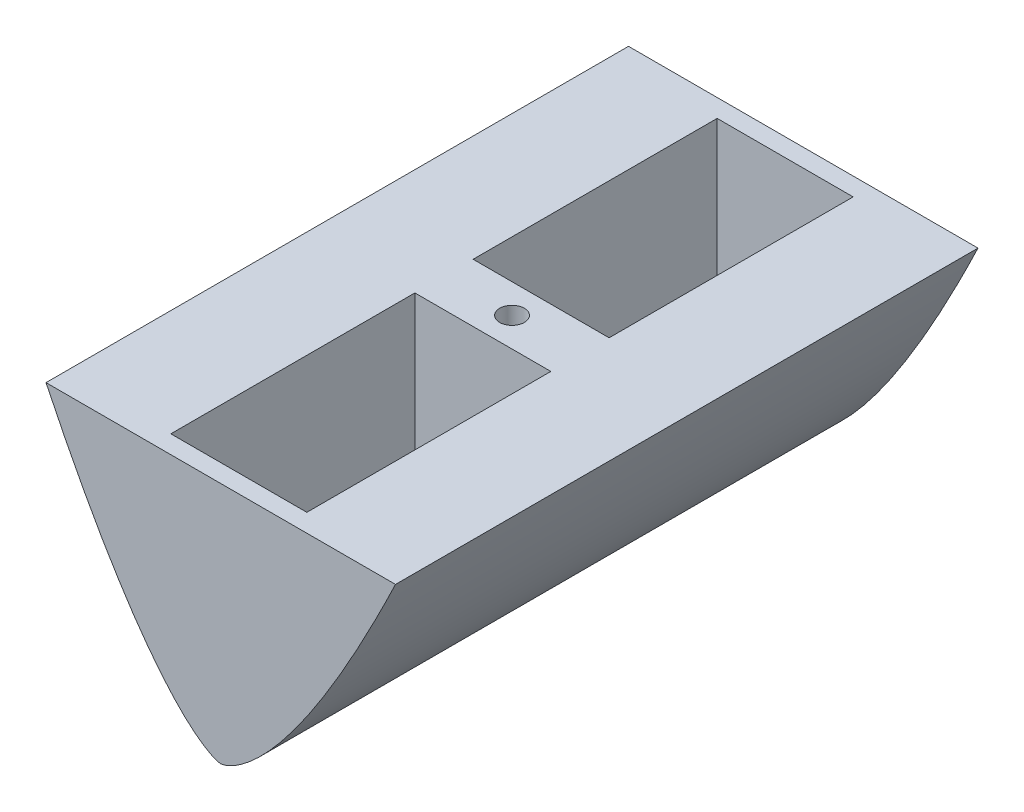
from build123d import *

# Parameters (mm, degrees)
BOSS_EXTRUDE1_DEPTH = 150
SKETCH2_W           = 70.04
SKETCH2_H           = 125.682
CUT_EXTRUDE1_DEPTH  = 92.52
SKETCH4_R           = 6.35
CUT_EXTRUDE2_DEPTH  = 126.0000001


with BuildPart() as part:
    # Sketch1 → Boss-Extrude1 (new body, symmetric)
    with BuildSketch(Plane.XY):
        with BuildLine():
            Line((-90, 0), (90, 0))
            add(Edge.make_bspline(
                [(0, -125), (0.040524176, -125), (0.132680738, -124.994439857), (0.341916524, -124.973583458), (0.719215848, -124.916748559), (1.289359309, -124.795671245), (2.111250987, -124.564993976), (3.188188494, -124.185399035), (4.55335692, -123.602067095), (6.240024265, -122.749483932), (8.303485367, -121.537471112), (10.724338253, -119.906336414), (13.709224486, -117.633146505), (17.125270454, -114.69999474), (20.824901988, -111.164506709), (25.639167248, -106.109725012), (30.222189081, -100.781084362), (34.598208113, -95.283505936), (38.779692195, -89.68464193), (42.033720965, -85.139153723), (45.998570642, -79.385140077), (50.607665842, -72.379869472), (55.055097052, -65.270591126), (59.364717318, -58.077727616), (62.873506602, -52.034941709), (65.634088968, -47.174450031), (68.351556299, -42.288964471), (71.027719256, -37.382091987), (73.66630476, -32.452622561), (76.267043416, -27.507038124), (78.515032858, -23.158839582), (80.417537293, -19.429534292), (81.996088861, -16.30213476), (83.240093312, -13.819613379), (84.499261394, -11.286158088), (85.71049431, -8.833707245), (86.985510696, -6.229974473), (88.124916321, -3.890806906), (89.16581329, -1.735067221), (89.725029899, -0.572854377), (90, 0)],
                knots=[0, 0, 0, 0, 0, 0.001033937, 0.002067874, 0.004832108, 0.008888532, 0.014521939, 0.021877134, 0.03129786, 0.043316303, 0.058339394, 0.077368645, 0.098985233, 0.130325067, 0.162749734, 0.196051037, 0.260900538, 0.293325324, 0.325750109, 0.358174889, 0.390599669, 0.455449159, 0.520298707, 0.552723499, 0.585148291, 0.617573035, 0.64999778, 0.682422553, 0.714847326, 0.747272095, 0.779696863, 0.795909248, 0.812121632, 0.828334016, 0.844546401, 0.860758801, 0.8769712, 0.8931836, 0.909396, 0.909396, 0.909396, 0.909396, 0.909396], degree=4))
            add(Edge.make_bspline(
                [(-90, 0), (-89.728779922, -0.56504183), (-89.1769697, -1.71190114), (-88.152296829, -3.83418854), (-87.025621632, -6.14778151), (-85.77024086, -8.712054514), (-84.575010931, -11.133133097), (-83.333486196, -13.632337314), (-82.107980727, -16.079385385), (-80.861307848, -18.551268163), (-79.614724115, -21.003198373), (-78.041946947, -24.073051937), (-76.14112023, -27.74330145), (-73.897620216, -32.01583355), (-71.29937439, -36.878159088), (-68.66345797, -41.721432974), (-65.319600127, -47.747831092), (-61.905775094, -53.735451599), (-58.415392446, -59.678580549), (-54.124522247, -66.749179037), (-50.456908111, -72.584773085), (-46.686198982, -78.354608666), (-42.019654617, -85.183243955), (-37.197162592, -91.90350945), (-31.965949682, -98.694375088), (-26.424011931, -105.23527848), (-21.505077303, -110.483804706), (-17.625792471, -114.241326427), (-14.180324535, -117.24850825), (-11.12345498, -119.618653213), (-8.635573143, -121.326761696), (-6.508658653, -122.601737804), (-4.768184737, -123.501182231), (-3.361883797, -124.117294089), (-2.239283334, -124.524207657), (-1.381983723, -124.772747972), (-0.756173, -124.911034051), (-0.347330621, -124.973877644), (-0.123395647, -124.995337069), (-0.020504111, -125), (0, -125)],
                knots=[0.090604, 0.090604, 0.090604, 0.090604, 0.090604, 0.106595296, 0.122586593, 0.138577889, 0.154569185, 0.17056047, 0.186551755, 0.202543039, 0.218534324, 0.234525598, 0.250516872, 0.282499419, 0.314481991, 0.346464563, 0.378447155, 0.410429746, 0.474394817, 0.506377414, 0.538360012, 0.602325099, 0.634307686, 0.666290273, 0.730255401, 0.794220554, 0.833134059, 0.865116625, 0.897099301, 0.919478736, 0.939186072, 0.954818476, 0.967077107, 0.976978528, 0.984613115, 0.990416572, 0.994763934, 0.997672431, 0.999476856, 1, 1, 1, 1, 1], degree=4))
        make_face()
    extrude(amount=BOSS_EXTRUDE1_DEPTH, both=True)

    # Sketch2 → Cut-Extrude1 (cut)
    with BuildSketch(Plane(origin=(0, 0, 0), x_dir=(1, 0, 0), z_dir=(0, 1, 0))):
        with Locations((0, 77.841)):
            Rectangle(SKETCH2_W, SKETCH2_H)
        with Locations((0, -77.841)):
            Rectangle(SKETCH2_W, SKETCH2_H)
    extrude(amount=-CUT_EXTRUDE1_DEPTH, mode=Mode.SUBTRACT)

    # Sketch4 → Cut-Extrude2 (cut, through all)
    with BuildSketch(Plane(origin=(0, 0, 0), x_dir=(1, 0, 0), z_dir=(0, 1, 0))):
        Circle(SKETCH4_R)
    extrude(amount=-CUT_EXTRUDE2_DEPTH, mode=Mode.SUBTRACT)


solid = part.part
